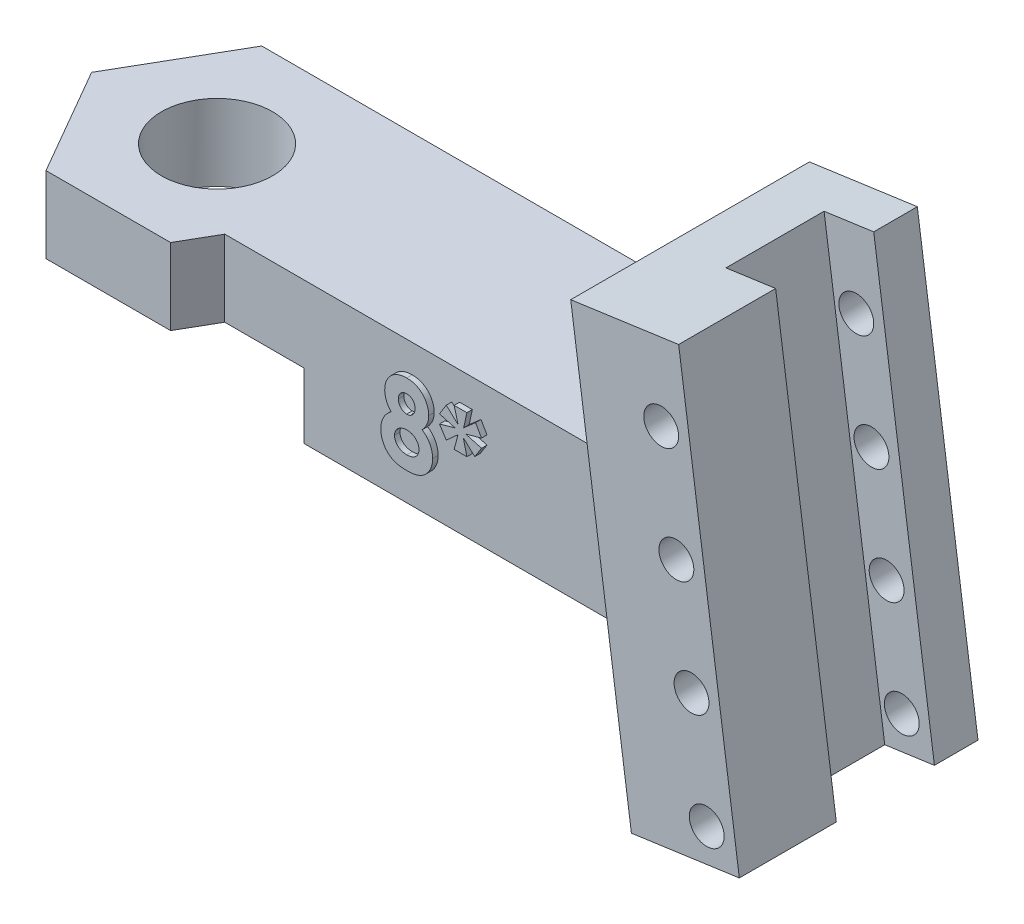
from build123d import *

# Parameters (mm, degrees)
SKETCH1_W                = 25
SKETCH1_H                = 6.75
BOSS_EXTRUDE1_DEPTH      = 6.5
BOSS_EXTRUDE4_DEPTH      = 6.5
BOSS_EXTRUDE3_DEPTH      = 6
BOSS_EXTRUDE3_DEPTH_BACK = 4.95
SKETCH4_W                = 2.3
SKETCH4_H                = 4.5
CUT_EXTRUDE1_DEPTH       = 23
SKETCH6_R                = 2.55
CUT_EXTRUDE2_DEPTH       = 10
BOSS_EXTRUDE5_DEPTH      = 1.575
CUT_EXTRUDE3_DEPTH       = 3
SKETCH9_R                = 0.8
CUT_EXTRUDE4_DEPTH       = 10.95
BOSS_EXTRUDE6_DEPTH      = 0.25


with BuildPart() as part:
    # Sketch1 → Boss-Extrude1 (new body)
    with BuildSketch(Plane(origin=(0, 0, 0), x_dir=(1, 0, 0), z_dir=(0, 1, 0))):
        with Locations((12.5, -3.375)):
            Rectangle(SKETCH1_W, SKETCH1_H)
    extrude(amount=BOSS_EXTRUDE1_DEPTH)

    # Sketch5 → Boss-Extrude4 (add)
    with BuildSketch(Plane(origin=(0, 6.5, 0), x_dir=(1, 0, 0), z_dir=(0, 1, 0))):
        Polygon((-5.715767665, -3.375), (-2.857883832, -8.325), (2.857883832, -8.325), (5.715767665, -3.375), (2.857883832, 1.575), (-2.857883832, 1.575), align=None)
    extrude(amount=-BOSS_EXTRUDE4_DEPTH)

    # Sketch3 → Boss-Extrude3 (add, two sides)
    with BuildSketch(Plane.XY.offset(3.375)) as boss_extrude3_sk:
        Polygon((22.265197637, 14.457428622), (27.216537981, 15.153294127), (30, -4.652067248), (25.048659656, -5.347932752), align=None)
    extrude(amount=BOSS_EXTRUDE3_DEPTH)
    extrude(boss_extrude3_sk.sketch, amount=-BOSS_EXTRUDE3_DEPTH_BACK)

    # Sketch4 → Cut-Extrude1 (cut)
    with BuildSketch(Plane(origin=(-1.561245701, 11.108840388, 0), x_dir=(0.990268069, 0.139173101, 0), z_dir=(-0.139173101, 0.990268069, 0))):
        with Locations((27.910599438, -2.675)):
            Rectangle(SKETCH4_W, SKETCH4_H)
    extrude(amount=-CUT_EXTRUDE1_DEPTH, mode=Mode.SUBTRACT)

    # Sketch6 → Cut-Extrude2 (cut)
    with BuildSketch(Plane(origin=(0, 6.5, 0), x_dir=(1, 0, 0), z_dir=(0, 1, 0))):
        with Locations((0, -3.335615973)):
            Circle(SKETCH6_R)
    extrude(amount=-CUT_EXTRUDE2_DEPTH, mode=Mode.SUBTRACT)

    # Sketch7 → Boss-Extrude5 (add)
    with BuildSketch(Plane(origin=(0, 0, -1.575), x_dir=(-1, 0, 0), z_dir=(0, 0, -1))):
        Polygon((-2.857883832, 0), (-24.297056723, 0), (-25.048659656, -5.347932752), (-30, -4.652067248), (-27.216537981, 15.153294127), (-22.265197637, 14.457428622), (-23.383541298, 6.5), (-2.857883832, 6.5), align=None)
    extrude(amount=-BOSS_EXTRUDE5_DEPTH)

    # Sketch8 → Cut-Extrude3 (cut)
    with BuildSketch(Plane(origin=(0, 0, 0), x_dir=(-1, 0, 0), z_dir=(0, -1, 0))):
        Polygon((-4.67653718, -11.475), (4.67653718, -11.475), (9.353074361, -3.375), (4.67653718, 4.725), (-4.67653718, 4.725), (-9.353074361, -3.375), align=None)
    extrude(amount=-CUT_EXTRUDE3_DEPTH, mode=Mode.SUBTRACT)

    # Sketch9 → Cut-Extrude4 (cut)
    with BuildSketch(Plane(origin=(0, 0, -1.575), x_dir=(-1, 0, 0), z_dir=(0, 0, -1))):
        with Locations((-28.503891859, -3.347590176)):
            Circle(SKETCH9_R)
        with Locations((-27.808026354, 1.603750168)):
            Circle(SKETCH9_R)
        with Locations((-27.11216085, 6.555090512)):
            Circle(SKETCH9_R)
        with Locations((-26.416295345, 11.506430855)):
            Circle(SKETCH9_R)
    extrude(amount=-CUT_EXTRUDE4_DEPTH, mode=Mode.SUBTRACT)

    # Sketch10 → Boss-Extrude6 (add)
    with BuildSketch(Plane.XY.offset(6.75)):
        with BuildLine():
            add(Edge.make_bspline(
                [(13.075824279, 3.505870833), (13.112526188, 3.479646328), (13.185174304, 3.427737286), (13.281115891, 3.334740296), (13.363755046, 3.231001076), (13.432223967, 3.11715594), (13.487079202, 2.996003232), (13.526347227, 2.86883793), (13.551289825, 2.736781662), (13.554014302, 2.646874072), (13.555391587, 2.601423718)],
                knots=[0, 0, 0, 0, 0.000135177, 0.00026757, 0.000399295, 0.000532042, 0.000665095, 0.000797263, 0.000930523, 0.001066759, 0.001066759, 0.001066759, 0.001066759], degree=3))
            add(Edge.make_bspline(
                [(13.555391587, 2.601423718), (13.553729997, 2.552208984), (13.550434446, 2.454597876), (13.521297375, 2.311451202), (13.474518976, 2.173928531), (13.410587165, 2.043547767), (13.330428432, 1.924360645), (13.236995974, 1.818846075), (13.130172012, 1.729759754), (13.030715877, 1.669315259), (12.945110507, 1.629163124), (12.876027725, 1.603466564), (12.803080848, 1.580844338), (12.725749337, 1.562770681), (12.644047255, 1.548661225), (12.5580912, 1.539343367), (12.46782459, 1.532569852), (12.406266578, 1.531870469), (12.374702484, 1.531511859)],
                knots=[0, 0, 0, 0, 0.000147517, 0.000292582, 0.000436255, 0.000582373, 0.000726855, 0.000865897, 0.001003783, 0.001142545, 0.001213746, 0.00128719, 0.00136348, 0.001442728, 0.001525259, 0.001612053, 0.001702019, 0.001796693, 0.001796693, 0.001796693, 0.001796693], degree=3))
            add(Edge.make_bspline(
                [(12.374702484, 1.531511859), (12.34104251, 1.531968442), (12.275311217, 1.532860058), (12.179358171, 1.538251244), (12.088846103, 1.5481905), (12.003585146, 1.561274762), (11.923657333, 1.578589031), (11.849060294, 1.600542577), (11.779613908, 1.625539131), (11.694607884, 1.66359853), (11.597461413, 1.723036433), (11.492463647, 1.810081526), (11.400302471, 1.913754952), (11.320177057, 2.031146614), (11.257019186, 2.161534316), (11.21005311, 2.300825615), (11.182239244, 2.448643048), (11.178890766, 2.549890722), (11.177186459, 2.601423718)],
                knots=[0, 0, 0, 0, 0.000100983, 0.000197201, 0.000288177, 0.000374052, 0.000455879, 0.000533311, 0.000607169, 0.000677148, 0.00081242, 0.000947344, 0.001084873, 0.00122722, 0.001372399, 0.001518066, 0.00166713, 0.001821645, 0.001821645, 0.001821645, 0.001821645], degree=3))
            add(Edge.make_bspline(
                [(11.177186459, 2.601423718), (11.17874391, 2.646377779), (11.18180449, 2.734717952), (11.203727837, 2.864164244), (11.241319715, 2.986894646), (11.292901623, 3.103763556), (11.359415618, 3.214783979), (11.441255024, 3.319139021), (11.537382202, 3.417770112), (11.610277236, 3.47601681), (11.647639183, 3.505870833)],
                knots=[0, 0, 0, 0, 0.000134836, 0.000264969, 0.000392498, 0.000519, 0.000647297, 0.000779691, 0.000916035, 0.001059397, 0.001059397, 0.001059397, 0.001059397], degree=3))
            add(Edge.make_bspline(
                [(11.647639183, 3.505870833), (11.624476758, 3.532585302), (11.578876918, 3.585178045), (11.519870277, 3.669821875), (11.470159667, 3.757089751), (11.427952992, 3.846273451), (11.396752741, 3.938908494), (11.37315816, 4.033538468), (11.359813087, 4.131127435), (11.357727212, 4.196905299), (11.356673638, 4.230129647)],
                knots=[0, 0, 0, 0, 0.000106018, 0.000208717, 0.000308899, 0.000407081, 0.000504196, 0.000601634, 0.000699302, 0.000798982, 0.000798982, 0.000798982, 0.000798982], degree=3))
            add(Edge.make_bspline(
                [(11.356673638, 4.230129647), (11.358070517, 4.275105619), (11.360826505, 4.363841481), (11.38523613, 4.493594261), (11.425762034, 4.616885263), (11.480894078, 4.733353509), (11.550903206, 4.840460699), (11.634089206, 4.936511905), (11.73162151, 5.017988809), (11.839873154, 5.087899589), (11.959386747, 5.143505974), (12.089028355, 5.182415159), (12.227232537, 5.207046724), (12.322478734, 5.209661558), (12.371196875, 5.210999038)],
                knots=[0, 0, 0, 0, 0.000134836, 0.000266026, 0.000394401, 0.000523295, 0.000651447, 0.000777159, 0.000903019, 0.001031378, 0.00116281, 0.001296988, 0.001436461, 0.001582498, 0.001582498, 0.001582498, 0.001582498], degree=3))
            add(Edge.make_bspline(
                [(12.371196875, 5.210999038), (12.419213348, 5.209659369), (12.512835415, 5.207047296), (12.648610844, 5.18257894), (12.775450872, 5.142803046), (12.892306625, 5.086022561), (12.999438737, 5.015977036), (13.095313405, 4.931663183), (13.178238365, 4.833219666), (13.248828613, 4.723341644), (13.305078193, 4.604963996), (13.346663309, 4.480820457), (13.370716631, 4.351886807), (13.374168234, 4.264346942), (13.375904407, 4.220313942)],
                knots=[0, 0, 0, 0, 0.000143937, 0.000280646, 0.000412357, 0.000541553, 0.000669119, 0.000795294, 0.000923131, 0.001054017, 0.001186046, 0.001315306, 0.001445807, 0.001577886, 0.001577886, 0.001577886, 0.001577886], degree=3))
            add(Edge.make_bspline(
                [(13.375904407, 4.220313942), (13.375068051, 4.189193799), (13.373426764, 4.128122845), (13.361291417, 4.038148095), (13.340856982, 3.951817201), (13.312366753, 3.867043901), (13.27275561, 3.781524431), (13.219152523, 3.693620084), (13.153951406, 3.599678417), (13.102745711, 3.538195515), (13.075824279, 3.505870833)],
                knots=[0, 0, 0, 0, 9.3344e-05, 0.000183181, 0.000271783, 0.00035914, 0.000451054, 0.000553861, 0.000667646, 0.000793787, 0.000793787, 0.000793787, 0.000793787], degree=3))
        make_face()
        with BuildLine():
            add(Edge.make_bspline(
                [(12.355772196, 4.58279391), (12.329907679, 4.581547001), (12.279595479, 4.579121487), (12.207805861, 4.55722854), (12.143264652, 4.521421069), (12.087445133, 4.472142941), (12.041670217, 4.412351315), (12.008028169, 4.343608623), (11.988078037, 4.266763226), (11.985965927, 4.212954622), (11.984878766, 4.185257852)],
                knots=[0, 0, 0, 0, 7.7441e-05, 0.000150641, 0.000222826, 0.000297356, 0.000372379, 0.000447321, 0.000525545, 0.000608518, 0.000608518, 0.000608518, 0.000608518], degree=3))
            add(Edge.make_bspline(
                [(11.984878766, 4.185257852), (11.986221742, 4.157324546), (11.988844033, 4.102782073), (12.0094654, 4.024460226), (12.044615091, 3.95347836), (12.092875379, 3.891319052), (12.151519444, 3.840549127), (12.217182819, 3.801773884), (12.290593723, 3.779638104), (12.341607256, 3.776636413), (12.367691266, 3.775101602)],
                knots=[0, 0, 0, 0, 8.3728e-05, 0.000163486, 0.000240934, 0.00031989, 0.000397917, 0.000472358, 0.000547102, 0.000625308, 0.000625308, 0.000625308, 0.000625308], degree=3))
            add(Edge.make_bspline(
                [(12.367691266, 3.775101602), (12.394268408, 3.776290817), (12.446045667, 3.778607632), (12.519639868, 3.801317774), (12.585938839, 3.837638019), (12.642714112, 3.888986809), (12.689741479, 3.951168628), (12.723990424, 4.023390965), (12.74370288, 4.104296855), (12.746334563, 4.160842645), (12.747699279, 4.190165705)],
                knots=[0, 0, 0, 0, 7.9536e-05, 0.000154952, 0.000228703, 0.000304687, 0.000382792, 0.000461195, 0.000542818, 0.000630738, 0.000630738, 0.000630738, 0.000630738], degree=3))
            add(Edge.make_bspline(
                [(12.747699279, 4.190165705), (12.746300041, 4.217844165), (12.743593963, 4.271373336), (12.724190348, 4.348223718), (12.688554638, 4.4158935), (12.641733913, 4.475313833), (12.583033271, 4.523232635), (12.514886126, 4.558472411), (12.437794284, 4.578911822), (12.383704957, 4.581471858), (12.355772196, 4.58279391)],
                knots=[0, 0, 0, 0, 8.3029e-05, 0.000160575, 0.00023552, 0.000310854, 0.000386083, 0.000461028, 0.000539431, 0.000623159, 0.000623159, 0.000623159, 0.000623159], degree=3))
        make_face(mode=Mode.SUBTRACT)
        with BuildLine():
            add(Edge.make_bspline(
                [(12.376104728, 3.146896474), (12.356449653, 3.146570072), (12.317709745, 3.145926738), (12.260758898, 3.138508134), (12.206108707, 3.127452579), (12.153826975, 3.112201752), (12.104177826, 3.091411037), (12.0567404, 3.066347446), (12.011678524, 3.036757618), (11.969660593, 3.003178756), (11.931686201, 2.966322756), (11.897455741, 2.927883143), (11.869477173, 2.886866148), (11.846177696, 2.84463519), (11.827456435, 2.800855611), (11.815080266, 2.754806452), (11.807111746, 2.707100957), (11.805968347, 2.674605909), (11.805391587, 2.658214583)],
                knots=[0, 0, 0, 0, 5.8932e-05, 0.000116154, 0.00017198, 0.000226107, 0.000279231, 0.000333176, 0.000386848, 0.00044072, 0.000494272, 0.000545454, 0.000594852, 0.000642862, 0.000689999, 0.000737287, 0.000785583, 0.000834742, 0.000834742, 0.000834742, 0.000834742], degree=3))
            add(Edge.make_bspline(
                [(11.805391587, 2.658214583), (11.805666481, 2.641120048), (11.806211699, 2.607215154), (11.814446451, 2.557728221), (11.826303041, 2.510001474), (11.842955999, 2.464481661), (11.865226167, 2.421195287), (11.891817152, 2.379721512), (11.92365617, 2.340351159), (11.959879918, 2.303295317), (12.000432243, 2.269864333), (12.044138762, 2.240411053), (12.090422212, 2.214443535), (12.140671989, 2.195740699), (12.193027143, 2.17862222), (12.248890287, 2.168236852), (12.307651268, 2.160595009), (12.347798346, 2.160014677), (12.368392388, 2.159716987)],
                knots=[0, 0, 0, 0, 5.1225e-05, 0.000101599, 0.000150062, 0.000198643, 0.000246617, 0.00029582, 0.000346189, 0.000398247, 0.000451032, 0.000503536, 0.000556247, 0.000609757, 0.000664089, 0.000721289, 0.000779903, 0.000841638, 0.000841638, 0.000841638, 0.000841638], degree=3))
            add(Edge.make_bspline(
                [(12.368392388, 2.159716987), (12.389209901, 2.160094329), (12.42977664, 2.160829649), (12.489077055, 2.167328488), (12.545164723, 2.177640254), (12.59797265, 2.192388482), (12.64770053, 2.211281549), (12.693681308, 2.235328685), (12.736964799, 2.262580782), (12.776160085, 2.294419382), (12.81194827, 2.32911681), (12.842784816, 2.36714224), (12.86900479, 2.407272912), (12.890154056, 2.449942438), (12.907219614, 2.4949494), (12.918925516, 2.542742566), (12.926189449, 2.592784851), (12.926850554, 2.626872412), (12.927186459, 2.644192147)],
                knots=[0, 0, 0, 0, 6.2435e-05, 0.000121667, 0.000178734, 0.00023334, 0.000285943, 0.000337996, 0.000388759, 0.000439127, 0.000489202, 0.00053804, 0.000585685, 0.000632718, 0.000680641, 0.000729785, 0.000780056, 0.000831981, 0.000831981, 0.000831981, 0.000831981], degree=3))
            add(Edge.make_bspline(
                [(12.927186459, 2.644192147), (12.926545079, 2.661738313), (12.925291405, 2.696034988), (12.918431482, 2.746682094), (12.905562968, 2.794696342), (12.888727192, 2.841191304), (12.866331744, 2.885204843), (12.83852828, 2.926644069), (12.806881113, 2.966535482), (12.769892568, 3.003103259), (12.729451345, 3.036539205), (12.68640811, 3.066326963), (12.640895439, 3.091554447), (12.592788842, 3.112176661), (12.541912548, 3.127460514), (12.488654744, 3.138507745), (12.433102794, 3.145928399), (12.395293068, 3.146570572), (12.376104728, 3.146896474)],
                knots=[0, 0, 0, 0, 5.2659e-05, 0.00010293, 0.000152926, 0.000201506, 0.000251049, 0.000300635, 0.000351004, 0.000403555, 0.00045634, 0.000508266, 0.000560361, 0.000612192, 0.000664977, 0.00071943, 0.000775261, 0.000832791, 0.000832791, 0.000832791, 0.000832791], degree=3))
        make_face(mode=Mode.SUBTRACT)
        Polygon((14.542571074, 5.210999038), (15.125904407, 5.210999038), (14.980071074, 4.537922115), (15.523440465, 5.013983814), (15.798981331, 4.537922115), (15.081032613, 4.335999038), (15.798981331, 4.134075961), (15.488384375, 3.647497435), (14.961841907, 4.134075961), (15.125904407, 3.460999038), (14.542571074, 3.460999038), (14.719954888, 4.134075961), (14.18149335, 3.647497435), (13.869494151, 4.134075961), (14.587442869, 4.335999038), (13.869494151, 4.537922115), (14.18149335, 5.036419711), (14.719954888, 4.537922115), align=None)
    extrude(amount=BOSS_EXTRUDE6_DEPTH)


solid = part.part
